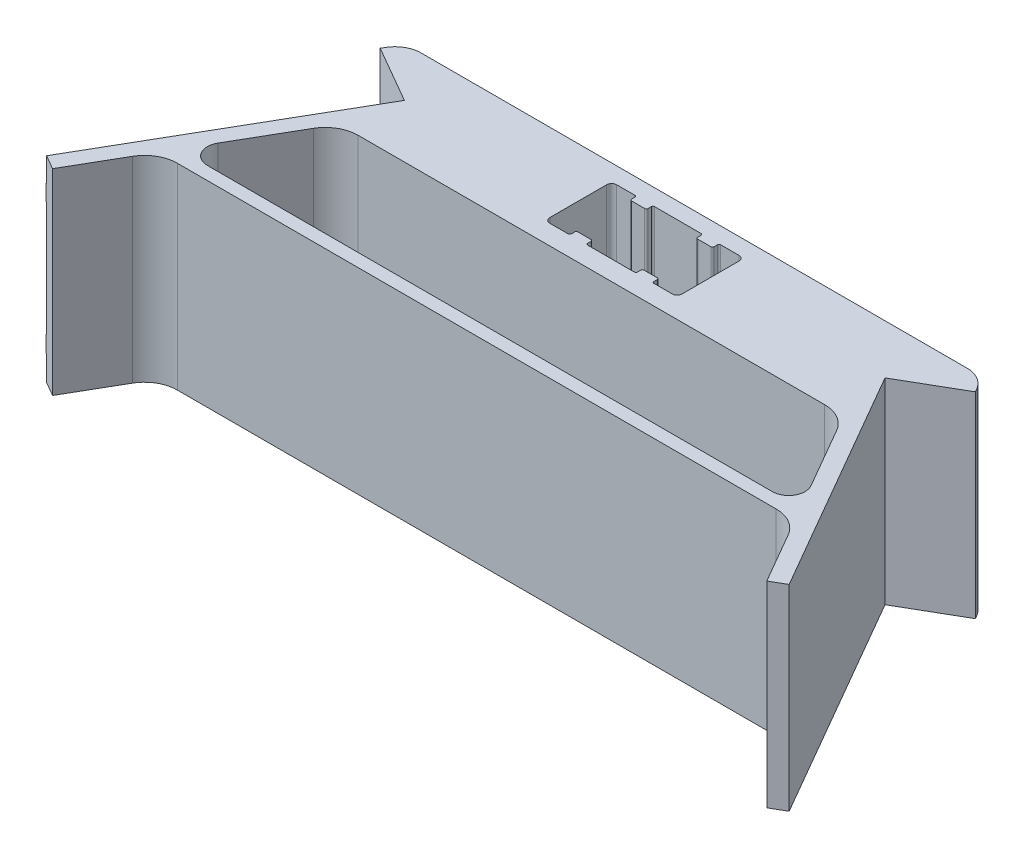
from build123d import *

# Parameters (mm, degrees)
BOSS_EXTRUDE3_DEPTH = 60
SKETCH6_W           = 80
SKETCH6_H           = 5
BOSS_EXTRUDE4_DEPTH = 0.5


with BuildPart() as part:
    # Sketch5 → Boss-Extrude3 (new body)
    with BuildSketch(Plane(origin=(0, 0, 0), x_dir=(1, 0, 0), z_dir=(0, 1, 0))):
        with BuildLine():
            Line((83.381197846, 5), (-83.381197846, 5))
            ThreePointArc((-83.381197846, 5), (-87.381197846, 3.92820323), (-90.309401077, 1))
            Line((-90.309401077, 1), (-90.886751346, 0))
            Line((-90.886751346, 0), (-73.39303819, -10.1))
            Line((-73.39303819, -10.1), (-113.39303819, -79.382032303))
            Line((-113.39303819, -79.382032303), (-109.062911171, -81.882032303))
            Line((-109.062911171, -81.882032303), (-100.124355653, -66.4))
            ThreePointArc((-100.124355653, -66.4), (-96.464101615, -62.739745962), (-91.464101615, -61.4))
            Line((-91.464101615, -61.4), (91.464101615, -61.4))
            ThreePointArc((91.464101615, -61.4), (96.464101615, -62.739745962), (100.124355653, -66.4))
            Line((100.124355653, -66.4), (109.062911171, -81.882032303))
            Line((109.062911171, -81.882032303), (113.39303819, -79.382032303))
            Line((113.39303819, -79.382032303), (73.39303819, -10.1))
            Line((73.39303819, -10.1), (90.886751346, 0))
            Line((90.886751346, 0), (90.309401077, 1))
            ThreePointArc((90.309401077, 1), (87.381197846, 3.92820323), (83.381197846, 5))
        make_face()
        with BuildLine():
            Line((7.1, -20.4), (-7.1, -20.4))
            ThreePointArc((-7.1, -20.4), (-7.453553391, -20.253553391), (-7.6, -19.9))
            Line((-7.6, -19.9), (-7.6, -18.9))
            ThreePointArc((-7.6, -18.9), (-7.746446609, -18.546446609), (-8.1, -18.4))
            Line((-8.1, -18.4), (-12.1, -18.4))
            ThreePointArc((-12.1, -18.4), (-12.453553391, -18.546446609), (-12.6, -18.9))
            Line((-12.6, -18.9), (-12.6, -19.9))
            ThreePointArc((-12.6, -19.9), (-12.746446609, -20.253553391), (-13.1, -20.4))
            Line((-13.1, -20.4), (-18.7, -20.4))
            ThreePointArc((-18.7, -20.4), (-19.760660172, -19.960660172), (-20.2, -18.9))
            Line((-20.2, -18.9), (-20.2, -1.5))
            ThreePointArc((-20.2, -1.5), (-19.760660172, -0.439339828), (-18.7, 0))
            Line((-18.7, 0), (-13.1, 0))
            ThreePointArc((-13.1, 0), (-12.746446609, -0.146446609), (-12.6, -0.5))
            Line((-12.6, -0.5), (-12.6, -1.5))
            ThreePointArc((-12.6, -1.5), (-12.453553391, -1.853553391), (-12.1, -2))
            Line((-12.1, -2), (-8.1, -2))
            ThreePointArc((-8.1, -2), (-7.746446609, -1.853553391), (-7.6, -1.5))
            Line((-7.6, -1.5), (-7.6, -0.5))
            ThreePointArc((-7.6, -0.5), (-7.453553391, -0.146446609), (-7.1, 0))
            Line((-7.1, 0), (7.1, 0))
            ThreePointArc((7.1, 0), (7.453553391, -0.146446609), (7.6, -0.5))
            Line((7.6, -0.5), (7.6, -1.5))
            ThreePointArc((7.6, -1.5), (7.746446609, -1.853553391), (8.1, -2))
            Line((8.1, -2), (12.1, -2))
            ThreePointArc((12.1, -2), (12.453553391, -1.853553391), (12.6, -1.5))
            Line((12.6, -1.5), (12.6, -0.5))
            ThreePointArc((12.6, -0.5), (12.746446609, -0.146446609), (13.1, 0))
            Line((13.1, 0), (18.7, 0))
            ThreePointArc((18.7, 0), (19.760660172, -0.439339828), (20.2, -1.5))
            Line((20.2, -1.5), (20.2, -18.9))
            ThreePointArc((20.2, -18.9), (19.760660172, -19.960660172), (18.7, -20.4))
            Line((18.7, -20.4), (13.1, -20.4))
            ThreePointArc((13.1, -20.4), (12.746446609, -20.253553391), (12.6, -19.9))
            Line((12.6, -19.9), (12.6, -18.9))
            ThreePointArc((12.6, -18.9), (12.453553391, -18.546446609), (12.1, -18.4))
            Line((12.1, -18.4), (8.1, -18.4))
            ThreePointArc((8.1, -18.4), (7.746446609, -18.546446609), (7.6, -18.9))
            Line((7.6, -18.9), (7.6, -19.9))
            ThreePointArc((7.6, -19.9), (7.453553391, -20.253553391), (7.1, -20.4))
        make_face(mode=Mode.SUBTRACT)
        with BuildLine():
            Line((-71.256842194, -26.4), (71.256842194, -26.4))
            ThreePointArc((71.256842194, -26.4), (76.256842194, -27.739745962), (79.917096231, -31.4))
            Line((79.917096231, -31.4), (90.598076211, -49.9))
            ThreePointArc((90.598076211, -49.9), (90.598076211, -54.9), (86.267949192, -57.4))
            Line((86.267949192, -57.4), (-86.267949192, -57.4))
            ThreePointArc((-86.267949192, -57.4), (-90.598076211, -54.9), (-90.598076211, -49.9))
            Line((-90.598076211, -49.9), (-79.917096231, -31.4))
            ThreePointArc((-79.917096231, -31.4), (-76.256842194, -27.739745962), (-71.256842194, -26.4))
        make_face(mode=Mode.SUBTRACT)
    extrude(amount=BOSS_EXTRUDE3_DEPTH)

    # Sketch6 → Boss-Extrude4 (add)
    with BuildSketch(Plane(origin=(-50.671350353, 0, -29.255117767), x_dir=(-0.5, 0, 0.866025404), z_dir=(-0.866025404, 0, -0.5))):
        with Locations((85.443375673, 50)):
            Rectangle(SKETCH6_W, SKETCH6_H)
        with Locations((85.443375673, 10)):
            Rectangle(SKETCH6_W, SKETCH6_H)
    extrude(amount=BOSS_EXTRUDE4_DEPTH)


solid = part.part
